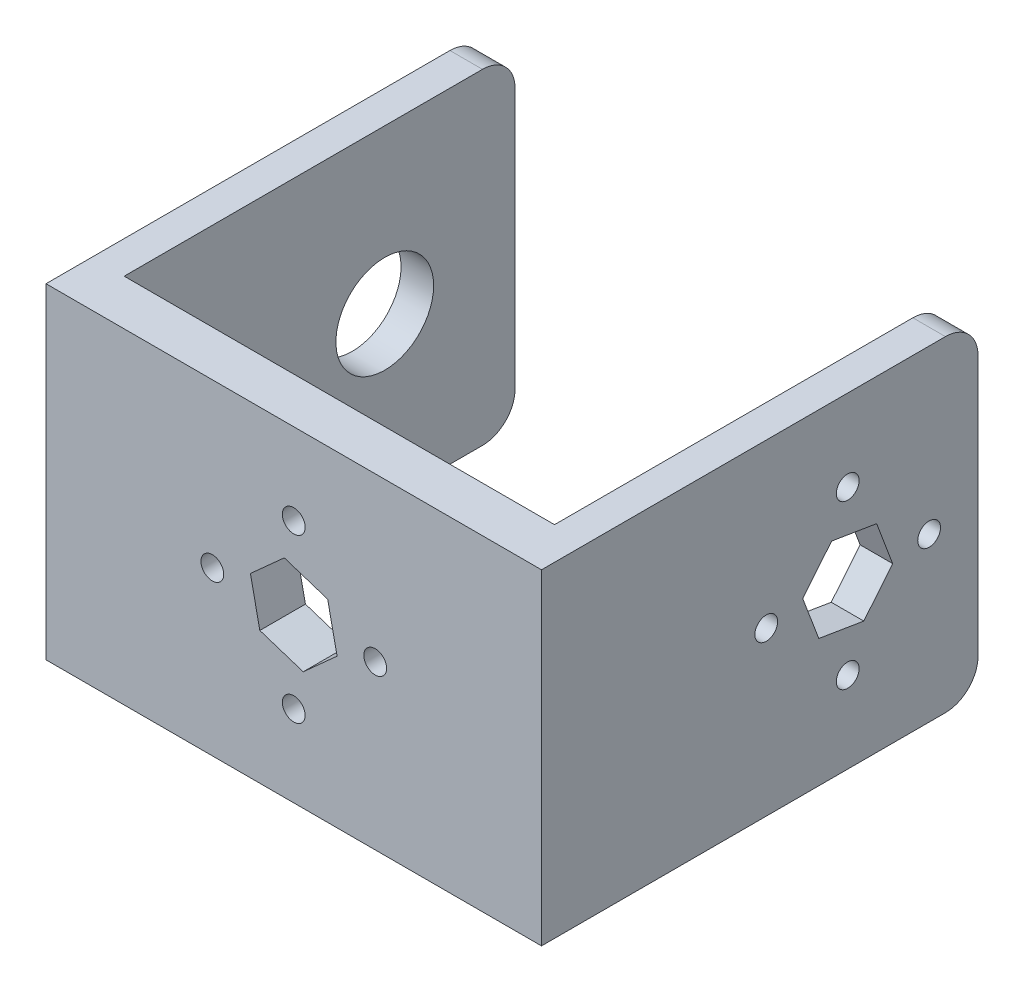
from build123d import *

# Parameters (mm, degrees)
BOSS_EXTRUDE1_DEPTH = 50
SKETCH3_R           = 7.5
CUT_EXTRUDE1_DEPTH  = 5
CUT_EXTRUDE2_DEPTH  = 5
CUT_EXTRUDE3_DEPTH  = 7
SKETCH4_3_R         = 1.75
CUT_EXTRUDE4_DEPTH  = 5
SKETCH5_3_R         = 1.75
CUT_EXTRUDE6_DEPTH  = 7
FILLET1_R           = 5


with BuildPart() as part:
    # Sketch1 → Boss-Extrude1 (new body)
    with BuildSketch(Plane(origin=(0, 0, 0), x_dir=(1, 0, 0), z_dir=(0, 1, 0))):
        Polygon((0, 0), (33.03, 0), (33.03, 60), (38.03, 60), (38.03, -7), (-38.03, -7), (-38.03, 60), (-33.03, 60), (-33.03, 0), align=None)
    extrude(amount=BOSS_EXTRUDE1_DEPTH)

    # Sketch3 → Cut-Extrude1 (cut)
    with BuildSketch(Plane(origin=(-33.03, 0, 0), x_dir=(0, 0, -1), z_dir=(1, 0, 0))):
        with Locations((40, 25)):
            Circle(SKETCH3_R)
    extrude(amount=-CUT_EXTRUDE1_DEPTH, mode=Mode.SUBTRACT)

    # Sketch4 → Cut-Extrude2 (cut)
    with BuildSketch(Plane.ZY.offset(-33.03)):
        Polygon((-46.907161244, 23.863723826), (-42.46953659, 18.450084807), (-35.562375345, 19.586360981), (-33.092838756, 26.136276174), (-37.53046341, 31.549915193), (-44.437624655, 30.413639019), align=None)
    extrude(amount=-CUT_EXTRUDE2_DEPTH, mode=Mode.SUBTRACT)

    # Sketch5 → Cut-Extrude3 (cut)
    with BuildSketch(Plane(origin=(0, 0, 0), x_dir=(-1, 0, 0), z_dir=(0, 0, -1))):
        Polygon((1.451740182, 31.847806251), (-5.204504082, 29.681147002), (-6.656244264, 22.833340752), (-1.451740182, 18.152193749), (5.204504082, 20.318852998), (6.656244264, 27.166659248), align=None)
    extrude(amount=-CUT_EXTRUDE3_DEPTH, mode=Mode.SUBTRACT)

    # Sketch4_3 → Cut-Extrude4 (cut)
    with BuildSketch(Plane.ZY.offset(-33.03)):
        with Locations((-52.5, 25)):
            Circle(SKETCH4_3_R)
        with Locations((-40, 37.5)):
            Circle(SKETCH4_3_R)
        with Locations((-40, 12.5)):
            Circle(SKETCH4_3_R)
        with Locations((-27.5, 25)):
            Circle(SKETCH4_3_R)
    extrude(amount=-CUT_EXTRUDE4_DEPTH, mode=Mode.SUBTRACT)

    # Sketch5_3 → Cut-Extrude6 (cut)
    with BuildSketch(Plane(origin=(0, 0, 0), x_dir=(-1, 0, 0), z_dir=(0, 0, -1))):
        with Locations((0, 37.5)):
            Circle(SKETCH5_3_R)
        with Locations((-12.5, 25)):
            Circle(SKETCH5_3_R)
        with Locations((0, 12.5)):
            Circle(SKETCH5_3_R)
        with Locations((12.5, 25)):
            Circle(SKETCH5_3_R)
    extrude(amount=-CUT_EXTRUDE6_DEPTH, mode=Mode.SUBTRACT)

    # Fillet1
    fillet1_edges = [part.edges().sort_by_distance(p)[0] for p in [
        (35.53, 0, -60),
        (-35.53, 0, -60),
        (-35.53, 50, -60),
        (35.53, 50, -60),
    ]]
    fillet(fillet1_edges, radius=FILLET1_R)


solid = part.part
